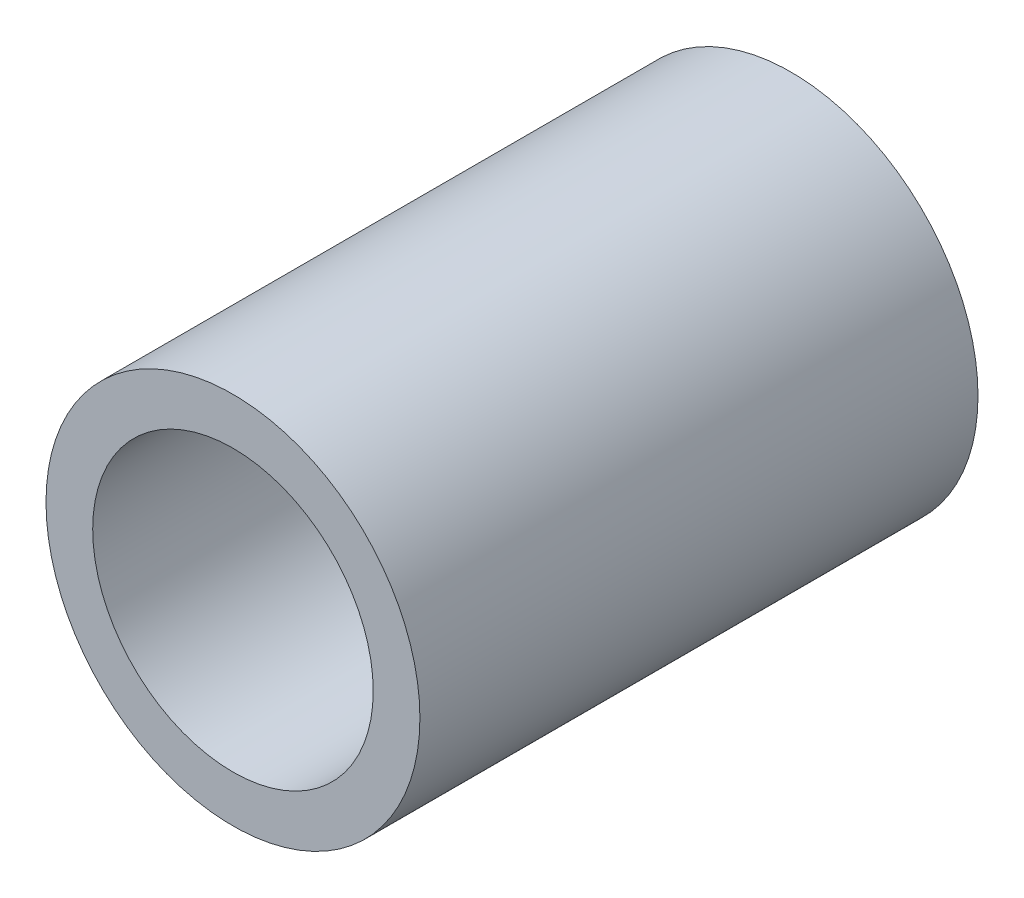
from build123d import *

# Parameters (mm, degrees)
SKETCH1_W = 19.05
SKETCH1_H = 1.59385


with BuildPart() as part:
    # Sketch1 → Revolve1 (revolve)
    with BuildSketch(Plane(origin=(0, 0, 0), x_dir=(0, 0, -1), z_dir=(1, 0, 0))):
        with Locations((0, 5.584825)):
            Rectangle(SKETCH1_W, SKETCH1_H)
    revolve(axis=Axis((0, 0, -9.525), (0, 0, 1)))


solid = part.part
